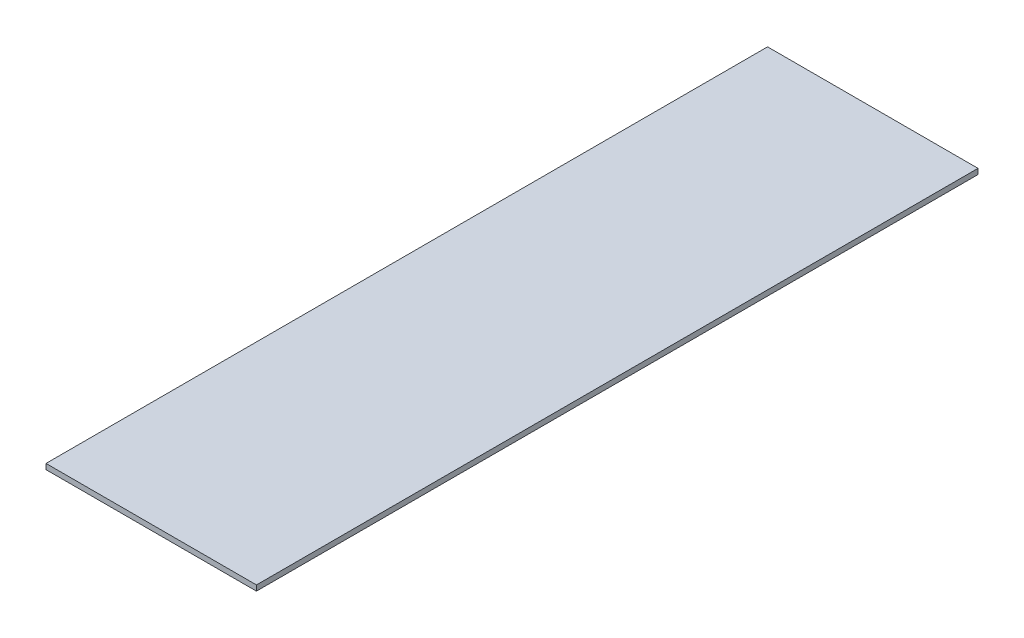
from build123d import *

# Parameters (mm, degrees)
SKETCH1_W           = 700
SKETCH1_H           = 2400
BOSS_EXTRUDE1_DEPTH = 18


with BuildPart() as part:
    # Sketch1 → Boss-Extrude1 (new body)
    with BuildSketch(Plane(origin=(0, 0, 0), x_dir=(1, 0, 0), z_dir=(0, 1, 0))):
        with Locations((350, 1200)):
            Rectangle(SKETCH1_W, SKETCH1_H)
    extrude(amount=BOSS_EXTRUDE1_DEPTH)


solid = part.part
